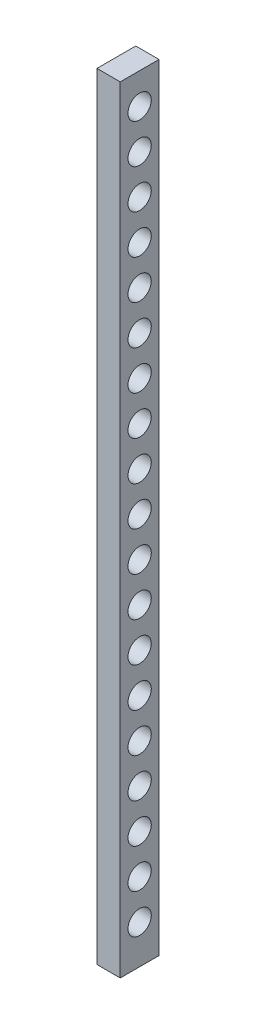
from build123d import *

# Parameters (mm, degrees)
EXTRUDE_1_DEPTH = 6


with BuildPart() as part:
    # 草图1 → 凸台-拉伸1 (new body)
    with BuildSketch(Plane(origin=(0, 0, 0), x_dir=(0, 0, -1), z_dir=(1, 0, 0))):
        with BuildLine():
            Line((5, -4.998144534), (5, 0))
            Line((5, 0), (0, 0))
            Line((0, 0), (0, -200))
            Line((0, -200), (5, -200))
            Line((5, -200), (5, -192.996545307))
            ThreePointArc((5, -192.996545307), (2, -189.996545307), (5, -186.996545307))
            Line((5, -186.996545307), (5, -182.885523042))
            ThreePointArc((5, -182.885523042), (2, -179.885523042), (5, -176.885523042))
            Line((5, -176.885523042), (5, -172.774500777))
            ThreePointArc((5, -172.774500777), (2, -169.774500777), (5, -166.774500777))
            Line((5, -166.774500777), (5, -162.663478512))
            ThreePointArc((5, -162.663478512), (2, -159.663478512), (5, -156.663478512))
            Line((5, -156.663478512), (5, -152.552456247))
            ThreePointArc((5, -152.552456247), (2, -149.552456247), (5, -146.552456247))
            Line((5, -146.552456247), (5, -142.441433981))
            ThreePointArc((5, -142.441433981), (2, -139.441433981), (5, -136.441433981))
            Line((5, -136.441433981), (5, -132.330411716))
            ThreePointArc((5, -132.330411716), (2, -129.330411716), (5, -126.330411716))
            Line((5, -126.330411716), (5, -122.219389451))
            ThreePointArc((5, -122.219389451), (2, -119.219389451), (5, -116.219389451))
            Line((5, -116.219389451), (5, -112.108367186))
            ThreePointArc((5, -112.108367186), (2, -109.108367186), (5, -106.108367186))
            Line((5, -106.108367186), (5, -101.99734492))
            ThreePointArc((5, -101.99734492), (2, -98.99734492), (5, -95.99734492))
            Line((5, -95.99734492), (5, -91.886322655))
            ThreePointArc((5, -91.886322655), (2, -88.886322655), (5, -85.886322655))
            Line((5, -85.886322655), (5, -81.77530039))
            ThreePointArc((5, -81.77530039), (2, -78.77530039), (5, -75.77530039))
            Line((5, -75.77530039), (5, -71.664278125))
            ThreePointArc((5, -71.664278125), (2, -68.664278125), (5, -65.664278125))
            Line((5, -65.664278125), (5, -61.55325586))
            ThreePointArc((5, -61.55325586), (2, -58.55325586), (5, -55.55325586))
            Line((5, -55.55325586), (5, -51.442233594))
            ThreePointArc((5, -51.442233594), (2, -48.442233594), (5, -45.442233594))
            Line((5, -45.442233594), (5, -41.331211329))
            ThreePointArc((5, -41.331211329), (2, -38.331211329), (5, -35.331211329))
            Line((5, -35.331211329), (5, -31.220189064))
            ThreePointArc((5, -31.220189064), (2, -28.220189064), (5, -25.220189064))
            Line((5, -25.220189064), (5, -21.109166799))
            ThreePointArc((5, -21.109166799), (2, -18.109166799), (5, -15.109166799))
            Line((5, -15.109166799), (5, -10.998144534))
            ThreePointArc((5, -10.998144534), (2, -7.998144534), (5, -4.998144534))
        make_face()
        with BuildLine():
            Line((10, 0), (5, 0))
            Line((5, 0), (5, -4.998144534))
            ThreePointArc((5, -4.998144534), (7.121320344, -5.87682419), (8, -7.998144534))
            ThreePointArc((8, -7.998144534), (7.121320344, -10.119464877), (5, -10.998144534))
            Line((5, -10.998144534), (5, -15.109166799))
            ThreePointArc((5, -15.109166799), (7.121320344, -15.987846455), (8, -18.109166799))
            ThreePointArc((8, -18.109166799), (7.121320344, -20.230487142), (5, -21.109166799))
            Line((5, -21.109166799), (5, -25.220189064))
            ThreePointArc((5, -25.220189064), (7.121320344, -26.09886872), (8, -28.220189064))
            ThreePointArc((8, -28.220189064), (7.121320344, -30.341509407), (5, -31.220189064))
            Line((5, -31.220189064), (5, -35.331211329))
            ThreePointArc((5, -35.331211329), (7.121320344, -36.209890986), (8, -38.331211329))
            ThreePointArc((8, -38.331211329), (7.121320344, -40.452531673), (5, -41.331211329))
            Line((5, -41.331211329), (5, -45.442233594))
            ThreePointArc((5, -45.442233594), (7.121320344, -46.320913251), (8, -48.442233594))
            ThreePointArc((8, -48.442233594), (7.121320344, -50.563553938), (5, -51.442233594))
            Line((5, -51.442233594), (5, -55.55325586))
            ThreePointArc((5, -55.55325586), (7.121320344, -56.431935516), (8, -58.55325586))
            ThreePointArc((8, -58.55325586), (7.121320344, -60.674576203), (5, -61.55325586))
            Line((5, -61.55325586), (5, -65.664278125))
            ThreePointArc((5, -65.664278125), (7.121320344, -66.542957781), (8, -68.664278125))
            ThreePointArc((8, -68.664278125), (7.121320344, -70.785598468), (5, -71.664278125))
            Line((5, -71.664278125), (5, -75.77530039))
            ThreePointArc((5, -75.77530039), (7.121320344, -76.653980046), (8, -78.77530039))
            ThreePointArc((8, -78.77530039), (7.121320344, -80.896620734), (5, -81.77530039))
            Line((5, -81.77530039), (5, -85.886322655))
            ThreePointArc((5, -85.886322655), (7.121320344, -86.765002312), (8, -88.886322655))
            ThreePointArc((8, -88.886322655), (7.121320344, -91.007642999), (5, -91.886322655))
            Line((5, -91.886322655), (5, -95.99734492))
            ThreePointArc((5, -95.99734492), (7.121320344, -96.876024577), (8, -98.99734492))
            ThreePointArc((8, -98.99734492), (7.121320344, -101.118665264), (5, -101.99734492))
            Line((5, -101.99734492), (5, -106.108367186))
            ThreePointArc((5, -106.108367186), (7.121320344, -106.987046842), (8, -109.108367186))
            ThreePointArc((8, -109.108367186), (7.121320344, -111.229687529), (5, -112.108367186))
            Line((5, -112.108367186), (5, -116.219389451))
            ThreePointArc((5, -116.219389451), (7.121320344, -117.098069107), (8, -119.219389451))
            ThreePointArc((8, -119.219389451), (7.121320344, -121.340709794), (5, -122.219389451))
            Line((5, -122.219389451), (5, -126.330411716))
            ThreePointArc((5, -126.330411716), (7.121320344, -127.209091373), (8, -129.330411716))
            ThreePointArc((8, -129.330411716), (7.121320344, -131.45173206), (5, -132.330411716))
            Line((5, -132.330411716), (5, -136.441433981))
            ThreePointArc((5, -136.441433981), (7.121320344, -137.320113638), (8, -139.441433981))
            ThreePointArc((8, -139.441433981), (7.121320344, -141.562754325), (5, -142.441433981))
            Line((5, -142.441433981), (5, -146.552456247))
            ThreePointArc((5, -146.552456247), (7.121320344, -147.431135903), (8, -149.552456247))
            ThreePointArc((8, -149.552456247), (7.121320344, -151.67377659), (5, -152.552456247))
            Line((5, -152.552456247), (5, -156.663478512))
            ThreePointArc((5, -156.663478512), (7.121320344, -157.542158168), (8, -159.663478512))
            ThreePointArc((8, -159.663478512), (7.121320344, -161.784798855), (5, -162.663478512))
            Line((5, -162.663478512), (5, -166.774500777))
            ThreePointArc((5, -166.774500777), (7.121320344, -167.653180433), (8, -169.774500777))
            ThreePointArc((8, -169.774500777), (7.121320344, -171.89582112), (5, -172.774500777))
            Line((5, -172.774500777), (5, -176.885523042))
            ThreePointArc((5, -176.885523042), (7.121320344, -177.764202699), (8, -179.885523042))
            ThreePointArc((8, -179.885523042), (7.121320344, -182.006843386), (5, -182.885523042))
            Line((5, -182.885523042), (5, -186.996545307))
            ThreePointArc((5, -186.996545307), (7.121320344, -187.875224964), (8, -189.996545307))
            ThreePointArc((8, -189.996545307), (7.121320344, -192.117865651), (5, -192.996545307))
            Line((5, -192.996545307), (5, -200))
            Line((5, -200), (10, -200))
            Line((10, -200), (10, 0))
        make_face()
    extrude(amount=EXTRUDE_1_DEPTH)


solid = part.part
